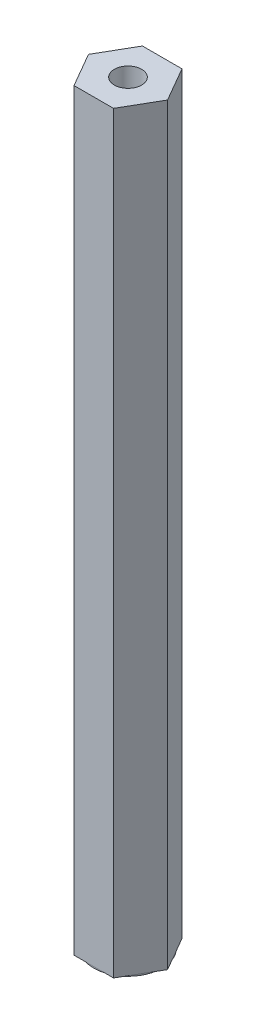
from build123d import *

# Parameters (mm, degrees)
BOSS_EXTRUDE1_DEPTH = 139.7
SKETCH2_R           = 2.54
CUT_EXTRUDE1_DEPTH  = 25.4
SKETCH3_R           = 6.35
BOSS_EXTRUDE2_DEPTH = 0.254


with BuildPart() as part:
    # Sketch1 → Boss-Extrude1 (new body)
    with BuildSketch(Plane(origin=(0, 0, 0), x_dir=(1, 0, 0), z_dir=(0, 1, 0))):
        Polygon((7.332348419, 0), (3.666174209, 6.35), (-3.666174209, 6.35), (-7.332348419, 0), (-3.666174209, -6.35), (3.666174209, -6.35), align=None)
    extrude(amount=BOSS_EXTRUDE1_DEPTH)

    # Sketch2 → Cut-Extrude1 (cut)
    with BuildSketch(Plane(origin=(0, 139.7, 0), x_dir=(1, 0, 0), z_dir=(0, 1, 0))):
        Circle(SKETCH2_R)
    extrude(amount=-CUT_EXTRUDE1_DEPTH, mode=Mode.SUBTRACT)

    # Sketch3 → Boss-Extrude2 (add)
    with BuildSketch(Plane.XZ):
        Circle(SKETCH3_R)
    extrude(amount=BOSS_EXTRUDE2_DEPTH)


solid = part.part
